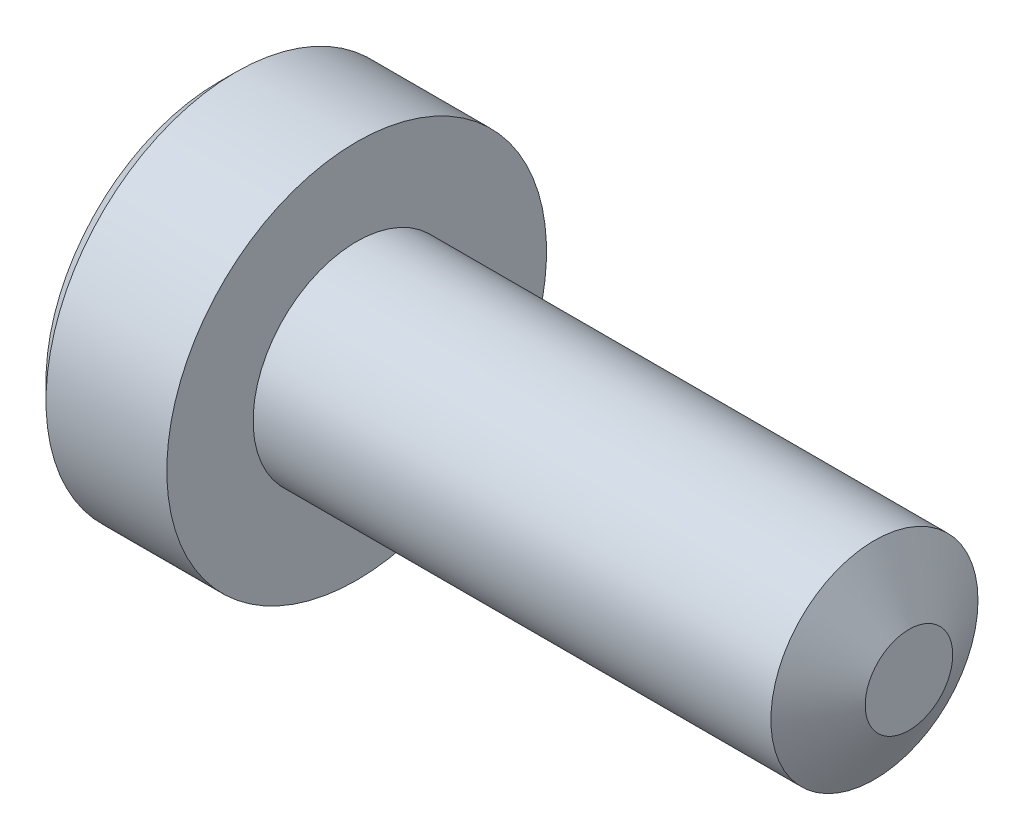
from build123d import *

# Parameters (mm, degrees)
SKETCH2_R              = 1.5
BOSS_EXTRUDE1_DEPTH    = 8
CHAMFER1_SIZE          = 0.375
CUT_SWEEP1_PITCH       = 0.5
CUT_SWEEP1_HEIGHT      = 8.5
CUT_SWEEP1_RADIUS      = 1.5
CUT_SWEEP1_START_ANGLE = -90
CUT_EXTRUDE1_DEPTH     = 1.62
SKETCH8_R              = 1.154700538
CUT_EXTRUDE2_DEPTH     = 11.0000001
CUT_EXTRUDE2_DRAFT     = -45
SKETCH9_R              = 1.5
BOSS_EXTRUDE2_DEPTH    = 8.38
CHAMFER2_SIZE          = 0.5
CHAMFER2_SIZE2         = 0.866025404


with BuildPart() as part:
    # Sketch2 → Boss-Extrude1 (new body)
    with BuildSketch(Plane(origin=(4, 0, 0), x_dir=(0, 0, -1), z_dir=(1, 0, 0))):
        Circle(SKETCH2_R)
    extrude(amount=-BOSS_EXTRUDE1_DEPTH)

    # Chamfer1
    chamfer1_edges = [part.edges().sort_by_distance(p)[0] for p in [
        (4, 0, 1.5),
    ]]
    chamfer(chamfer1_edges, length=CHAMFER1_SIZE)

    # Cut-Sweep1: sweep along a helix
    with BuildLine() as cut_sweep1_path:
        add(Helix(CUT_SWEEP1_PITCH, CUT_SWEEP1_HEIGHT, CUT_SWEEP1_RADIUS, center=(4, 0, 0), direction=(-1, 0, 0), mode=Mode.PRIVATE).rotate(Axis((4, 0, 0), (-1, 0, 0)), CUT_SWEEP1_START_ANGLE))
    # Sketch5 → Cut-Sweep1 (sweep, cut)
    with BuildSketch(Plane.XY):
        Polygon((3.78125, 1.5), (4.21875, 1.5), (4.03125, 1.175240474), (3.96875, 1.175240474), align=None)
    sweep(path=cut_sweep1_path.line, is_frenet=True, mode=Mode.SUBTRACT)

    # Sketch6 → Revolve1 (revolve)
    with BuildSketch(Plane.XY):
        Polygon((-5.75, 2.75), (-6, 2.5), (-6, 0), (-4, 0), (-4, 2.75), align=None)
    revolve(axis=Axis((-4, 0, 0), (-1, 0, 0)))

    # Sketch4 → Cut-Extrude1 (cut)
    with BuildSketch(Plane(origin=(-6, 0, 0), x_dir=(0, 0, -1), z_dir=(1, 0, 0))):
        Polygon((0, 1.154700538), (-1, 0.577350269), (-1, -0.577350269), (0, -1.154700538), (1, -0.577350269), (1, 0.577350269), align=None)
    extrude(amount=CUT_EXTRUDE1_DEPTH, mode=Mode.SUBTRACT)


with BuildPart() as cut_extrude2_tool:
    # Sketch8 → Cut-Extrude2 (with draft: the straight prism first)
    with BuildSketch(Plane.ZY.offset(6)):
        Circle(SKETCH8_R)
    extrude(amount=-CUT_EXTRUDE2_DEPTH)
    # Cut-Extrude2: the draft: its side faces are tilted about the plane it starts from
    cut_extrude2_sides = [cut_extrude2_tool.faces().sort_by_distance(p)[0] for p in [
        (-0.49999995, 0, -1.154700538),
    ]]
    draft(cut_extrude2_sides, Plane.ZY.offset(6), CUT_EXTRUDE2_DRAFT)


with BuildPart() as part_1:
    add(part.part)

    # Cut-Extrude2: cut by cut_extrude2_tool
    add(cut_extrude2_tool.part, mode=Mode.SUBTRACT)

    # Sketch9 → Boss-Extrude2 (add)
    with BuildSketch(Plane(origin=(4, 0, 0), x_dir=(0, 0, -1), z_dir=(1, 0, 0))):
        Circle(SKETCH9_R)
    extrude(amount=-BOSS_EXTRUDE2_DEPTH)

    # Chamfer2
    chamfer2_edges = [part_1.edges().sort_by_distance(p)[0] for p in [
        (4, 0, 1.5),
    ]]
    chamfer2_side = [part_1.faces().sort_by_distance(p)[0] for p in [
        (0, 0, 1.5),
    ]]
    chamfer(chamfer2_edges, length=CHAMFER2_SIZE, length2=CHAMFER2_SIZE2, reference=chamfer2_side[0])


solid = part_1.part
